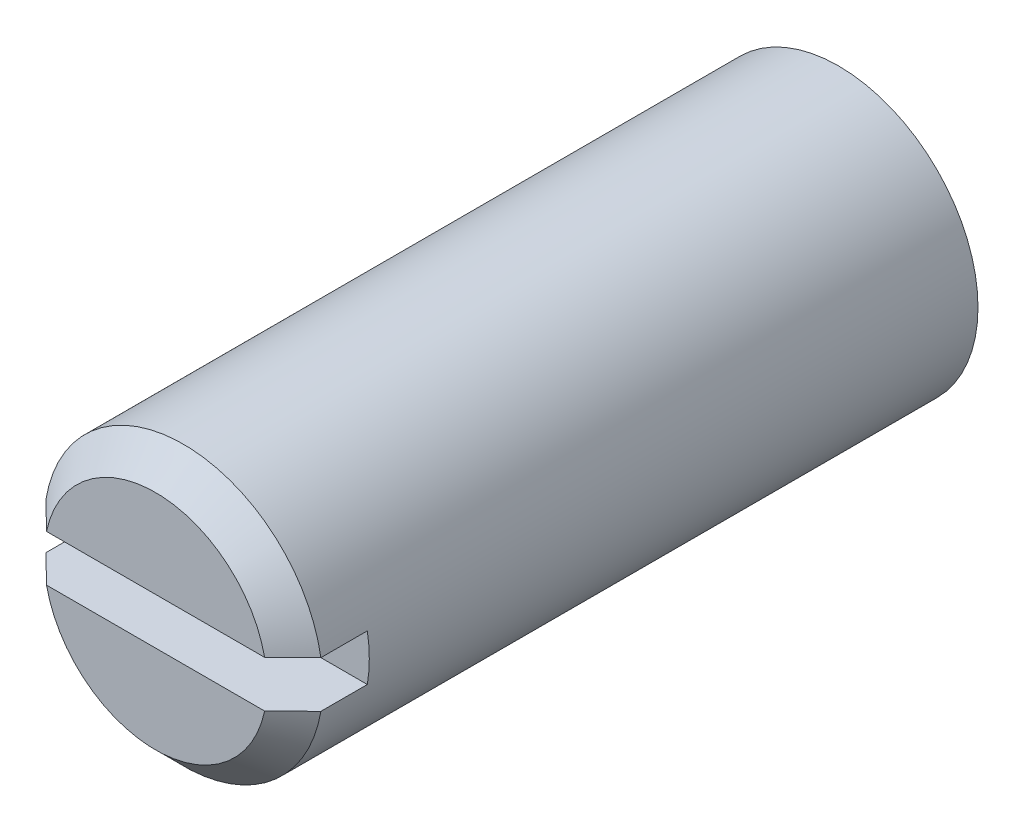
from build123d import *

# Parameters (mm, degrees)
SKETCH_2_W               = 1.6
SKETCH_2_H               = 1
CUT_EXTRUDE_1_DEPTH      = 4
CUT_EXTRUDE_1_DEPTH_BACK = 4
CHAMFER_1_SIZE           = 0.6


with BuildPart() as part:
    # Эскиз1 → Повернуть1 (revolve)
    with BuildSketch(Plane(origin=(0, 0, 0), x_dir=(1, 0, 0), z_dir=(0, 1, 0))):
        Polygon((0, 0), (-3, 0), (-3, 14.700961894), (-0.75, 16), (0, 16), align=None)
    revolve(axis=Axis((0, 0, -16), (0, 0, 1)))

    # Эскиз2 → Вырез-Вытянуть1 (cut, two sides)
    with BuildSketch(Plane(origin=(0, 0, 0), x_dir=(0, 0, -1), z_dir=(1, 0, 0))) as cut_extrude_1_sk:
        with Locations((0.8, 0)):
            Rectangle(SKETCH_2_W, SKETCH_2_H)
    extrude(amount=CUT_EXTRUDE_1_DEPTH, mode=Mode.SUBTRACT)
    extrude(cut_extrude_1_sk.sketch, amount=-CUT_EXTRUDE_1_DEPTH_BACK, mode=Mode.SUBTRACT)

    # Фаска1
    chamfer_1_edges = [part.edges().sort_by_distance(p)[0] for p in [
        (0, 3, 0),
        (0, -3, 0),
    ]]
    chamfer(chamfer_1_edges, length=CHAMFER_1_SIZE)


solid = part.part
